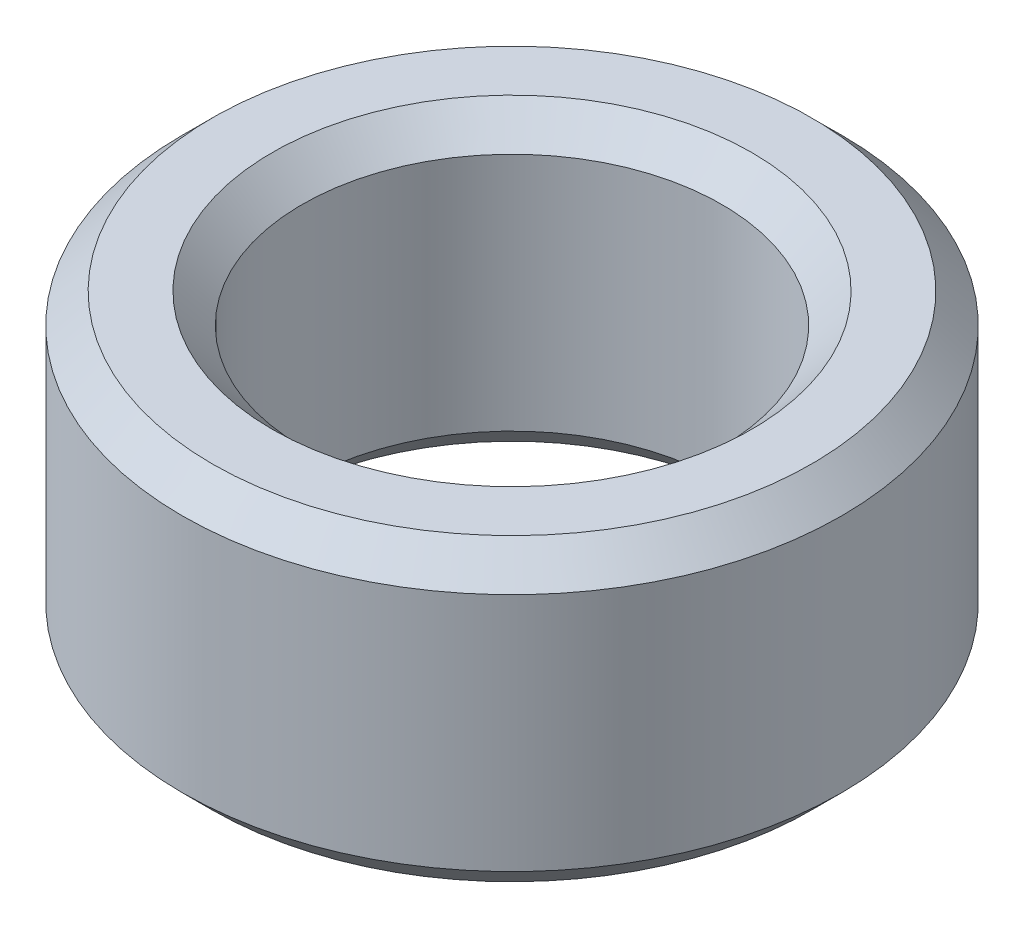
from build123d import *

# Parameters (mm, degrees)
SKETCH2_R           = 2.75
SKETCH2_R_2         = 1.75
BOSS_EXTRUDE1_DEPTH = 2.5
CHAMFER1_SIZE       = 0.25
CHAMFER2_SIZE       = 0.25
CHAMFER3_SIZE       = 0.25
CHAMFER4_SIZE       = 0.25


with BuildPart() as part:
    # Sketch2 → Boss-Extrude1 (new body)
    with BuildSketch(Plane(origin=(0, 0, 0), x_dir=(1, 0, 0), z_dir=(0, 1, 0))):
        Circle(SKETCH2_R)
        Circle(SKETCH2_R_2, mode=Mode.SUBTRACT)
    extrude(amount=BOSS_EXTRUDE1_DEPTH)

    # Chamfer1
    chamfer1_edges = [part.edges().sort_by_distance(p)[0] for p in [
        (-2.75, 2.5, 0),
    ]]
    chamfer(chamfer1_edges, length=CHAMFER1_SIZE)

    # Chamfer2
    chamfer2_edges = [part.edges().sort_by_distance(p)[0] for p in [
        (-2.75, 0, 0),
    ]]
    chamfer(chamfer2_edges, length=CHAMFER2_SIZE)

    # Chamfer3
    chamfer3_edges = [part.edges().sort_by_distance(p)[0] for p in [
        (-1.75, 2.5, 0),
    ]]
    chamfer(chamfer3_edges, length=CHAMFER3_SIZE)

    # Chamfer4
    chamfer4_edges = [part.edges().sort_by_distance(p)[0] for p in [
        (-1.75, 0, 0),
    ]]
    chamfer(chamfer4_edges, length=CHAMFER4_SIZE)


solid = part.part
